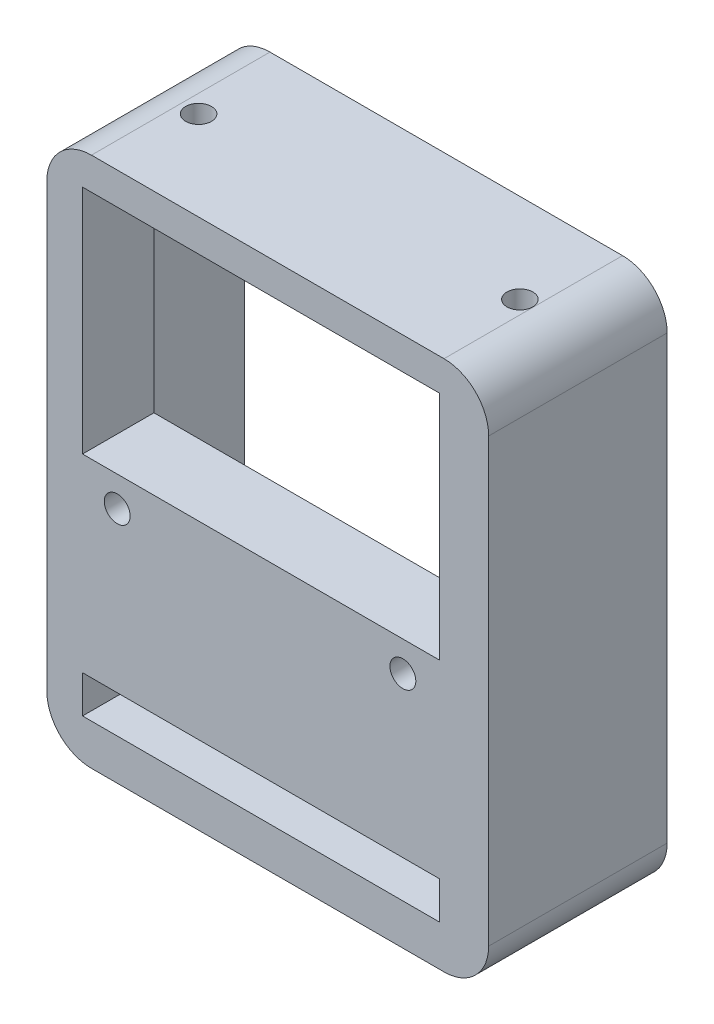
from build123d import *

# Parameters (mm, degrees)
EXTRUDE_1_DEPTH     = 20
SKETCH_2_W          = 45.2
SKETCH_2_H          = 55.2
CUT_EXTRUDE_1_DEPTH = 12
SKETCH_4_W          = 40
SKETCH_4_H          = 25.9
SKETCH_4_H_2        = 4.2
CUT_EXTRUDE_2_DEPTH = 44.561737798
SKETCH_6_R          = 1.45
CUT_EXTRUDE_4_DEPTH = 41.516971753
SKETCH_8_R          = 1.45
CUT_EXTRUDE_6_DEPTH = 6
SKETCH_9_R          = 1.45
CUT_EXTRUDE_7_DEPTH = 6


with BuildPart() as part:
    # 草图1 → 凸台-拉伸1 (new body)
    with BuildSketch(Plane.XY):
        with BuildLine():
            Line((-19.75, 29.75), (19.75, 29.75))
            ThreePointArc((19.75, 29.75), (23.285533906, 28.285533906), (24.75, 24.75))
            Line((24.75, 24.75), (24.75, -24.75))
            ThreePointArc((24.75, -24.75), (23.285533906, -28.285533906), (19.75, -29.75))
            Line((19.75, -29.75), (-19.75, -29.75))
            ThreePointArc((-19.75, -29.75), (-23.285533906, -28.285533906), (-24.75, -24.75))
            Line((-24.75, -24.75), (-24.75, 24.75))
            ThreePointArc((-24.75, 24.75), (-23.285533906, 28.285533906), (-19.75, 29.75))
        make_face()
    extrude(amount=EXTRUDE_1_DEPTH)

    # 草图2 → 切除-拉伸1 (cut)
    with BuildSketch(Plane(origin=(0, 0, 0), x_dir=(-1, 0, 0), z_dir=(0, 0, -1))):
        Rectangle(SKETCH_2_W, SKETCH_2_H)
    extrude(amount=-CUT_EXTRUDE_1_DEPTH, mode=Mode.SUBTRACT)

    # 草图4 → 切除-拉伸2 (cut, through all)
    with BuildSketch(Plane.XY.offset(20)):
        with Locations((-0.75, 13.2)):
            Rectangle(SKETCH_4_W, SKETCH_4_H)
        with Locations((-0.75, -23.065049662)):
            Rectangle(SKETCH_4_W, SKETCH_4_H_2)
    extrude(amount=-CUT_EXTRUDE_2_DEPTH, mode=Mode.SUBTRACT)

    # 草图6 → 切除-拉伸4 (cut, through all)
    with BuildSketch(Plane(origin=(0, 0, 12), x_dir=(-1, 0, 0), z_dir=(0, 0, -1))):
        with Locations((16.862, -3.116)):
            Circle(SKETCH_6_R)
        with Locations((-15.138, -3.116)):
            Circle(SKETCH_6_R)
    extrude(amount=-CUT_EXTRUDE_4_DEPTH, mode=Mode.SUBTRACT)

    # 草图8 → 切除-拉伸6 (cut)
    with BuildSketch(Plane(origin=(0, 29.75, 0), x_dir=(1, 0, 0), z_dir=(0, 1, 0))):
        with Locations((-17.75, -10)):
            Circle(SKETCH_8_R)
        with Locations((18.25, -10)):
            Circle(SKETCH_8_R)
    extrude(amount=-CUT_EXTRUDE_6_DEPTH, mode=Mode.SUBTRACT)

    # 草图9 → 切除-拉伸7 (cut)
    with BuildSketch(Plane.XZ.offset(29.75)):
        with Locations((-10, 10)):
            Circle(SKETCH_9_R)
        with Locations((10, 10)):
            Circle(SKETCH_9_R)
    extrude(amount=-CUT_EXTRUDE_7_DEPTH, mode=Mode.SUBTRACT)


solid = part.part
